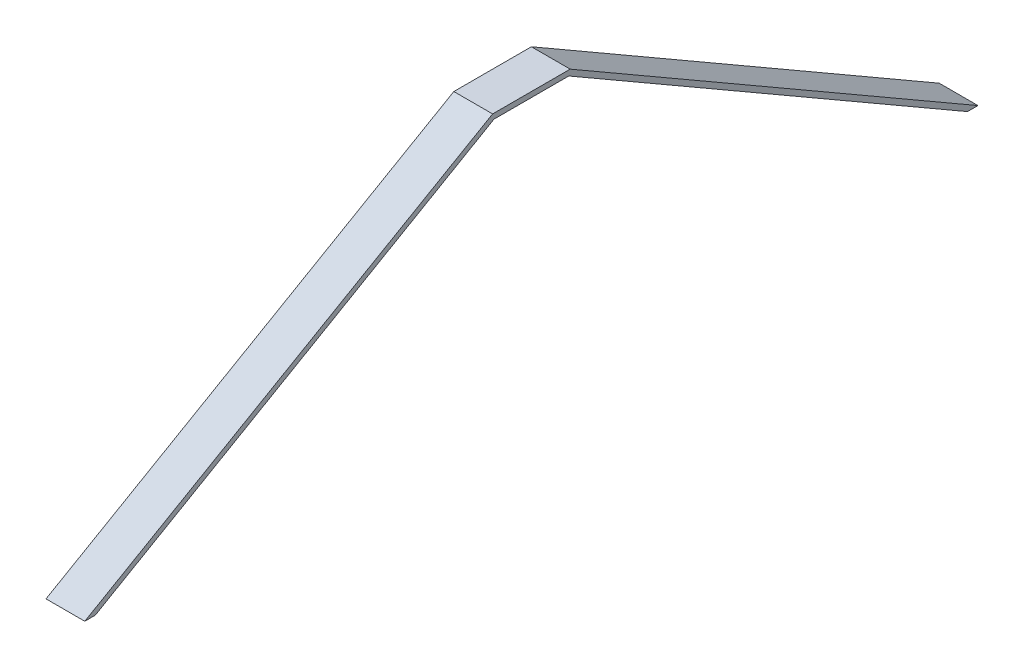
from build123d import *

# Parameters (mm, degrees)
BOSS_EXTRUDE1_DEPTH = 155


with BuildPart() as part:
    # Sketch2 → Boss-Extrude1 (new body)
    with BuildSketch(Plane(origin=(0, 0, 0), x_dir=(0, 0, -1), z_dir=(1, 0, 0))):
        Polygon((155, 941), (0, 941), (-155, 941), (-1784.859809922, 0), (-1742.859809922, 0), (-149.373066959, 920), (149.373066959, 920), (1742.859809922, 0), (1784.859809922, 0), align=None)
    extrude(amount=BOSS_EXTRUDE1_DEPTH)


solid = part.part
